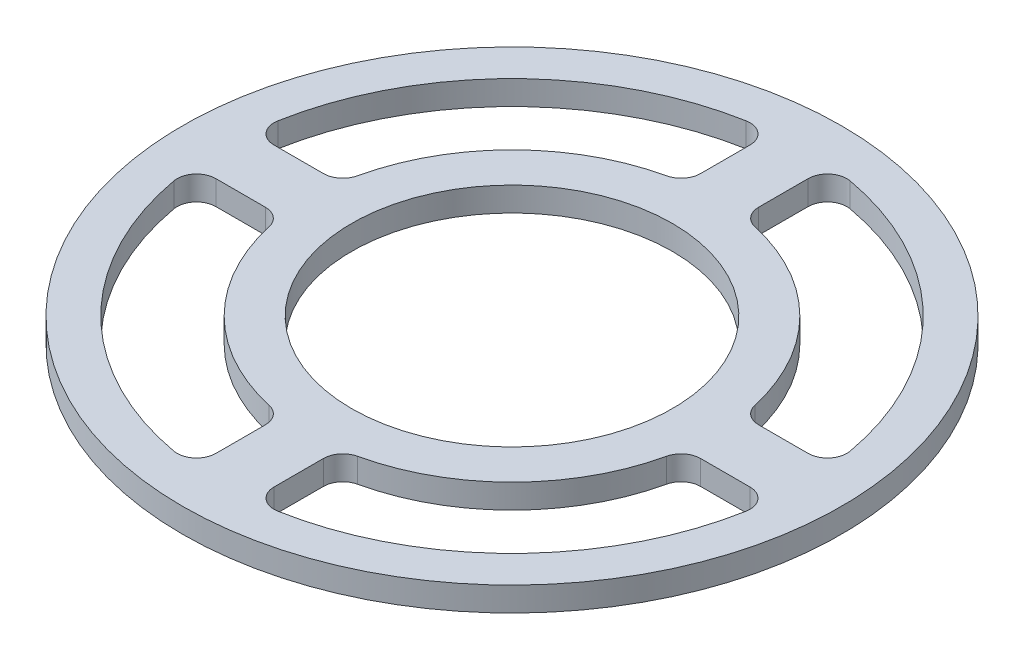
from build123d import *

# Parameters (mm, degrees)
SKETCH_1_R      = 34
SKETCH_1_R_2    = 16.55
EXTRUDE_1_DEPTH = 2.5


with BuildPart() as part:
    # 草图1 → 凸台-拉伸1 (new body)
    with BuildSketch(Plane(origin=(0, 2.5, 0), x_dir=(1, 0, 0), z_dir=(0, 1, 0))):
        Circle(SKETCH_1_R)
        Circle(SKETCH_1_R_2, mode=Mode.SUBTRACT)
        with BuildLine():
            Line((-3, -22.449944321), (-3, -27.549954628))
            ThreePointArc((-3, -27.549954628), (-3.718260111, -29.085253575), (-5.357142857, -29.51780853))
            ThreePointArc((-5.357142857, -29.51780853), (-21.213203436, -21.213203436), (-29.51780853, -5.357142857))
            ThreePointArc((-29.51780853, -5.357142857), (-29.085253575, -3.718260111), (-27.549954628, -3))
            Line((-27.549954628, -3), (-22.449944321, -3))
            ThreePointArc((-22.449944321, -3), (-21.198857836, -3.439621005), (-20.497775249, -4.565217391))
            ThreePointArc((-20.497775249, -4.565217391), (-14.849242405, -14.849242405), (-4.565217391, -20.497775249))
            ThreePointArc((-4.565217391, -20.497775249), (-3.439621005, -21.198857836), (-3, -22.449944321))
        make_face(mode=Mode.SUBTRACT)
        with BuildLine():
            Line((-22.449944321, 3), (-27.549954628, 3))
            ThreePointArc((-27.549954628, 3), (-29.085253575, 3.718260111), (-29.51780853, 5.357142857))
            ThreePointArc((-29.51780853, 5.357142857), (-21.213203436, 21.213203436), (-5.357142857, 29.51780853))
            ThreePointArc((-5.357142857, 29.51780853), (-3.718260111, 29.085253575), (-3, 27.549954628))
            Line((-3, 27.549954628), (-3, 22.449944321))
            ThreePointArc((-3, 22.449944321), (-3.439621005, 21.198857836), (-4.565217391, 20.497775249))
            ThreePointArc((-4.565217391, 20.497775249), (-14.849242405, 14.849242405), (-20.497775249, 4.565217391))
            ThreePointArc((-20.497775249, 4.565217391), (-21.198857836, 3.439621005), (-22.449944321, 3))
        make_face(mode=Mode.SUBTRACT)
        with BuildLine():
            Line((3, 22.449944321), (3, 27.549954628))
            ThreePointArc((3, 27.549954628), (3.718260111, 29.085253575), (5.357142857, 29.51780853))
            ThreePointArc((5.357142857, 29.51780853), (21.213203436, 21.213203436), (29.51780853, 5.357142857))
            ThreePointArc((29.51780853, 5.357142857), (29.085253575, 3.718260111), (27.549954628, 3))
            Line((27.549954628, 3), (22.449944321, 3))
            ThreePointArc((22.449944321, 3), (21.198857836, 3.439621005), (20.497775249, 4.565217391))
            ThreePointArc((20.497775249, 4.565217391), (14.849242405, 14.849242405), (4.565217391, 20.497775249))
            ThreePointArc((4.565217391, 20.497775249), (3.439621005, 21.198857836), (3, 22.449944321))
        make_face(mode=Mode.SUBTRACT)
        with BuildLine():
            Line((22.449944321, -3), (27.549954628, -3))
            ThreePointArc((27.549954628, -3), (29.085253575, -3.718260111), (29.51780853, -5.357142857))
            ThreePointArc((29.51780853, -5.357142857), (21.213203436, -21.213203436), (5.357142857, -29.51780853))
            ThreePointArc((5.357142857, -29.51780853), (3.718260111, -29.085253575), (3, -27.549954628))
            Line((3, -27.549954628), (3, -22.449944321))
            ThreePointArc((3, -22.449944321), (3.439621005, -21.198857836), (4.565217391, -20.497775249))
            ThreePointArc((4.565217391, -20.497775249), (14.849242405, -14.849242405), (20.497775249, -4.565217391))
            ThreePointArc((20.497775249, -4.565217391), (21.198857836, -3.439621005), (22.449944321, -3))
        make_face(mode=Mode.SUBTRACT)
    extrude(amount=-EXTRUDE_1_DEPTH)


solid = part.part
